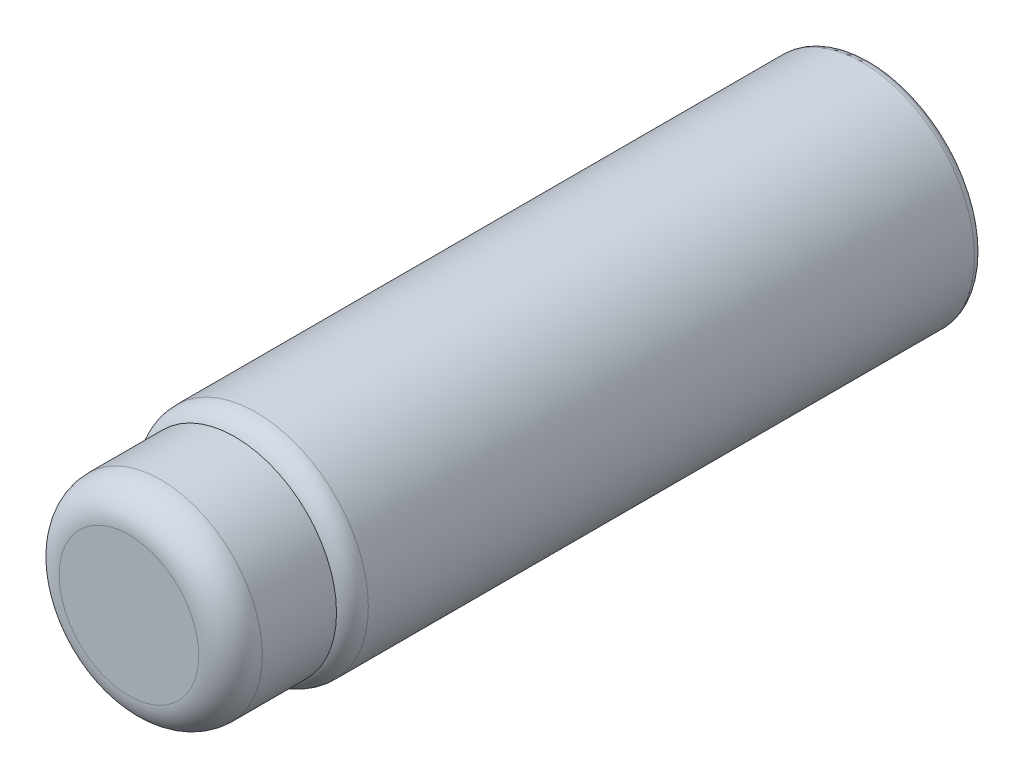
from build123d import *

# Parameters (mm, degrees)
SKETCH1_R           = 52.936641772
BOSS_EXTRUDE1_DEPTH = 300
FILLET1_R           = 10
SKETCH2_R           = 47.936641772
BOSS_EXTRUDE2_DEPTH = 50
FILLET2_R           = 15
SKETCH3_R           = 43.922720163
CUT_EXTRUDE1_DEPTH  = 10
FILLET3_R           = 5
FILLET4_R           = 4


with BuildPart() as part:
    # Sketch1 → Boss-Extrude1 (new body)
    with BuildSketch(Plane.XY):
        Circle(SKETCH1_R)
    extrude(amount=BOSS_EXTRUDE1_DEPTH)

    # Fillet1
    fillet1_edges = [part.edges().sort_by_distance(p)[0] for p in [
        (-52.936641772, 0, 300),
    ]]
    fillet(fillet1_edges, radius=FILLET1_R)

    # Sketch2 → Boss-Extrude2 (add)
    with BuildSketch(Plane.XY.offset(300)):
        Circle(SKETCH2_R)
    extrude(amount=BOSS_EXTRUDE2_DEPTH)

    # Fillet2
    fillet2_edges = [part.edges().sort_by_distance(p)[0] for p in [
        (-47.936641772, 0, 350),
    ]]
    fillet(fillet2_edges, radius=FILLET2_R)

    # Sketch3 → Cut-Extrude1 (cut)
    with BuildSketch(Plane(origin=(0, 0, 0), x_dir=(-1, 0, 0), z_dir=(0, 0, -1))):
        Circle(SKETCH3_R)
    extrude(amount=-CUT_EXTRUDE1_DEPTH, mode=Mode.SUBTRACT)

    # Fillet3
    fillet3_edges = [part.edges().sort_by_distance(p)[0] for p in [
        (43.922720163, 0, 0),
    ]]
    fillet(fillet3_edges, radius=FILLET3_R)

    # Fillet4
    fillet4_edges = [part.edges().sort_by_distance(p)[0] for p in [
        (-52.936641772, 0, 0),
    ]]
    fillet(fillet4_edges, radius=FILLET4_R)


solid = part.part
